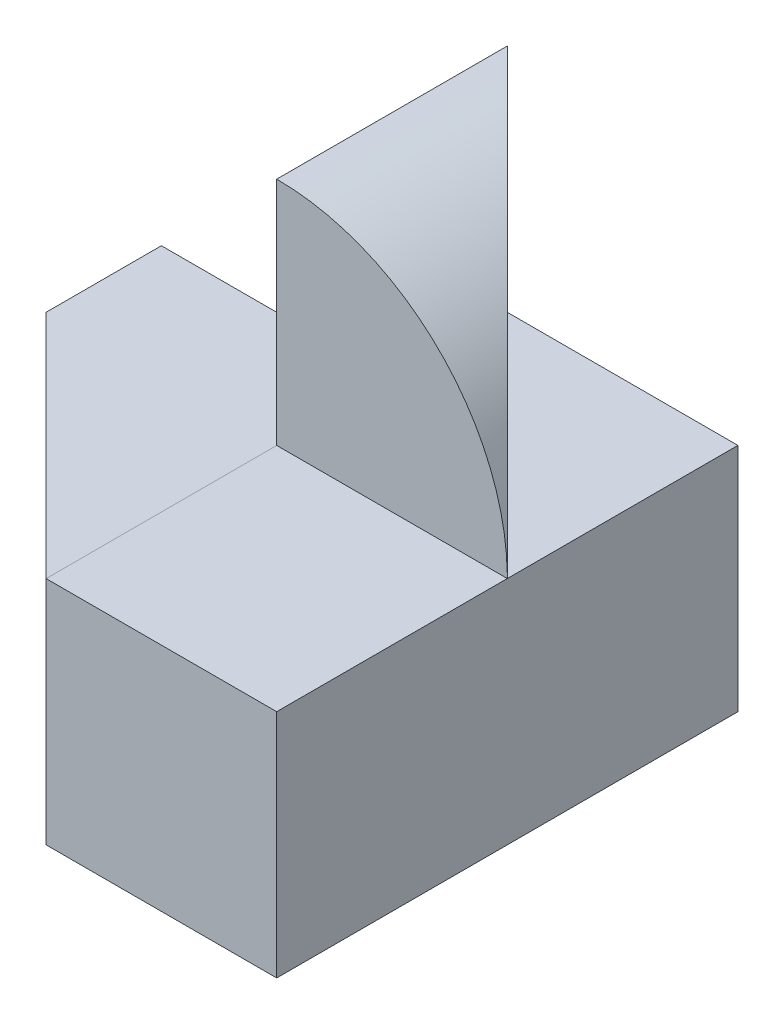
from build123d import *

# Parameters (mm, degrees)
SKETCH1_W           = 4
SKETCH1_H           = 4
BOSS_EXTRUDE1_DEPTH = 4
CUT_EXTRUDE1_DEPTH  = 4
CUT_EXTRUDE2_DEPTH  = 4
SKETCH4_W           = 2
SKETCH4_H           = 2
CUT_EXTRUDE3_DEPTH  = 4
CUT_EXTRUDE4_DEPTH  = 10
CUT_EXTRUDE5_DEPTH  = 1
CUT_EXTRUDE6_DEPTH  = 2


with BuildPart() as part:
    # Sketch1 → Boss-Extrude1 (new body)
    with BuildSketch(Plane(origin=(0, 0, 0), x_dir=(1, 0, 0), z_dir=(0, 1, 0))):
        Rectangle(SKETCH1_W, SKETCH1_H)
    extrude(amount=BOSS_EXTRUDE1_DEPTH)

    # Sketch2 → Cut-Extrude1 (cut)
    with BuildSketch(Plane.XY.offset(2)):
        Polygon((0.000305194, 2.000000023), (0, 4), (-2, 4), (-2, 2), align=None)
        with BuildLine():
            Line((2, 4), (0, 4))
            ThreePointArc((0, 4), (1.402002953, 3.426619591), (2, 2.034938268))
            Line((2, 2.034938268), (2, 4))
        make_face()
    extrude(amount=-CUT_EXTRUDE1_DEPTH, mode=Mode.SUBTRACT)

    # Sketch3 → Cut-Extrude2 (cut)
    with BuildSketch(Plane(origin=(-2.3e-08, 2.000000023, 0), x_dir=(1, 1.2e-08, 0), z_dir=(-1.2e-08, 1, 0))):
        Polygon((0.00030524, -2), (-1.999999977, 0), (-1.999999977, -2), align=None)
    extrude(amount=-CUT_EXTRUDE2_DEPTH, mode=Mode.SUBTRACT)

    # Sketch4 → Cut-Extrude3 (cut)
    with BuildSketch(Plane(origin=(0.000610387, 9.3e-08, 0), x_dir=(0, 0, 1), z_dir=(-0.999999988, -0.000152597, 0))):
        with Locations((1, 2.999999953)):
            Rectangle(SKETCH4_W, SKETCH4_H)
    extrude(amount=-CUT_EXTRUDE3_DEPTH, mode=Mode.SUBTRACT)

    # Sketch5 → Cut-Extrude4 (cut)
    with BuildSketch(Plane(origin=(-0.000305194, 1.99999993, 0), x_dir=(0.999999988, 0.000152597, 0), z_dir=(-0.000152597, 0.999999988, 0))):
        Polygon((2.000310502, 0), (0.000915581, 2), (2.000310502, 2), align=None)
    extrude(amount=CUT_EXTRUDE4_DEPTH, mode=Mode.SUBTRACT)

    # Sketch6 → Cut-Extrude5 (cut)
    with BuildSketch(Plane(origin=(0, 0, -2), x_dir=(-1, 0, 0), z_dir=(0, 0, -1))):
        Polygon((2, 0), (-0.000305194, 2.000000023), (2, 2.000000012), align=None)
    extrude(amount=-CUT_EXTRUDE5_DEPTH, mode=Mode.SUBTRACT)

    # Sketch7 → Cut-Extrude6 (cut)
    with BuildSketch(Plane.XY.offset(2)):
        with BuildLine():
            Line((-2, 2), (-1.999999977, 0))
            Line((-1.999999977, 0), (0.00030524, 0))
            ThreePointArc((0.00030524, 0), (-1.414105641, 0.585678515), (-2, 2))
        make_face()
    extrude(amount=-CUT_EXTRUDE6_DEPTH, mode=Mode.SUBTRACT)


solid = part.part
